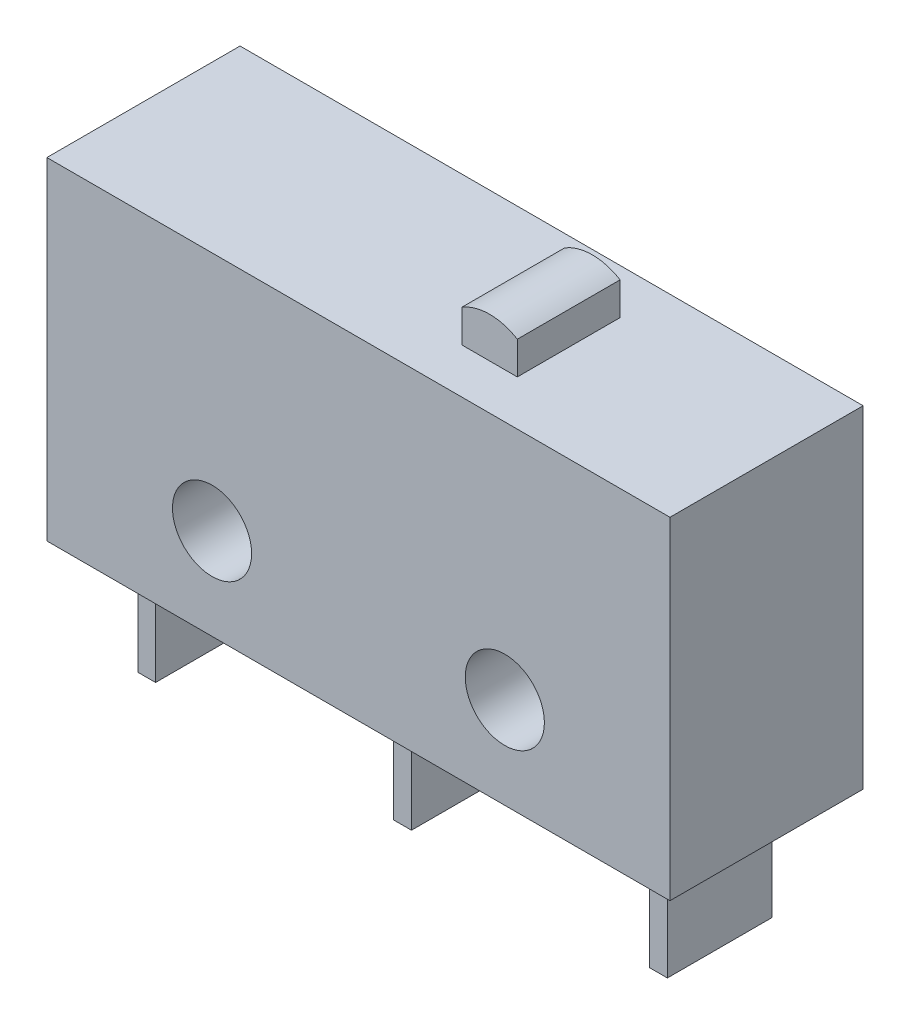
from build123d import *

# Parameters (mm, degrees)
SKETCH1_W           = 20
SKETCH1_H           = 10.66
BOSS_EXTRUDE1_DEPTH = 3.1
SKETCH2_R           = 1.27
CUT_EXTRUDE1_DEPTH  = 7.2
SKETCH3_W           = 0.5715
SKETCH3_H           = 3.3655
BOSS_EXTRUDE2_DEPTH = 3.6068
SKETCH4_W           = 1.778
SKETCH4_H           = 3.3
BOSS_EXTRUDE3_DEPTH = 1.3
CUT_EXTRUDE2_DEPTH  = 5.75


with BuildPart() as part:
    # Sketch1 → Boss-Extrude1 (new body, symmetric)
    with BuildSketch(Plane.XY):
        with Locations((0, 5.33)):
            Rectangle(SKETCH1_W, SKETCH1_H)
    extrude(amount=BOSS_EXTRUDE1_DEPTH, both=True)

    # Sketch2 → Cut-Extrude1 (cut, through all)
    with BuildSketch(Plane.XY.offset(3.1)):
        with Locations((4.699, 2.9337)):
            Circle(SKETCH2_R)
        with Locations((-4.699, 2.9337)):
            Circle(SKETCH2_R)
    extrude(amount=-CUT_EXTRUDE1_DEPTH, mode=Mode.SUBTRACT)

    # Sketch3 → Boss-Extrude2 (add)
    with BuildSketch(Plane.XZ):
        with Locations((-8.21425, 0)):
            Rectangle(SKETCH3_W, SKETCH3_H)
        Rectangle(SKETCH3_W, SKETCH3_H)
        with Locations((8.21425, 0)):
            Rectangle(SKETCH3_W, SKETCH3_H)
    extrude(amount=BOSS_EXTRUDE2_DEPTH)

    # Sketch4 → Boss-Extrude3 (add)
    with BuildSketch(Plane(origin=(0, 10.66, 0), x_dir=(1, 0, 0), z_dir=(0, 1, 0))):
        with Locations((2.761, 0)):
            Rectangle(SKETCH4_W, SKETCH4_H)
    extrude(amount=BOSS_EXTRUDE3_DEPTH)

    # Sketch5 → Cut-Extrude2 (cut, through all)
    with BuildSketch(Plane.XY.offset(1.65)):
        with BuildLine():
            Line((1.872, 11.96), (1.872, 11.71))
            ThreePointArc((1.872, 11.71), (2.29925846, 11.896310917), (2.761, 11.96))
            Line((2.761, 11.96), (1.872, 11.96))
        make_face()
        with BuildLine():
            ThreePointArc((2.761, 11.96), (3.22274154, 11.896310917), (3.65, 11.71))
            Line((3.65, 11.71), (3.65, 11.96))
            Line((3.65, 11.96), (2.761, 11.96))
        make_face()
    extrude(amount=-CUT_EXTRUDE2_DEPTH, mode=Mode.SUBTRACT)


solid = part.part
